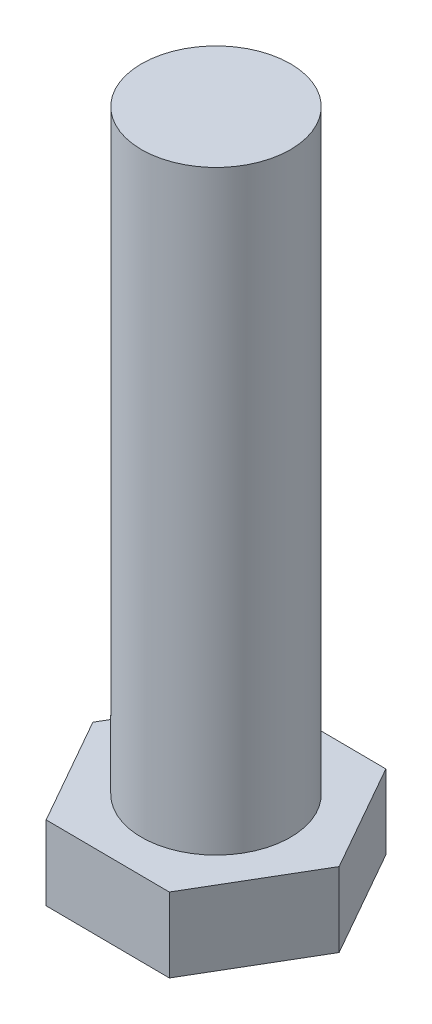
from build123d import *

# Parameters (mm, degrees)
SKETCH1_R           = 1.5
BOSS_EXTRUDE1_DEPTH = 12
BOSS_EXTRUDE2_DEPTH = 1.5


with BuildPart() as part:
    # Sketch1 → Boss-Extrude1 (new body)
    with BuildSketch(Plane(origin=(0, 0, 0), x_dir=(1, 0, 0), z_dir=(0, 1, 0))):
        Circle(SKETCH1_R)
    extrude(amount=BOSS_EXTRUDE1_DEPTH)

    # Sketch2 → Boss-Extrude2 (add)
    with BuildSketch(Plane.XZ):
        Polygon((2.5, 0.018896825), (1.23363487, 2.174511922), (-1.26636513, 2.155615097), (-2.5, -0.018896825), (-1.23363487, -2.174511922), (1.26636513, -2.155615097), align=None)
    extrude(amount=BOSS_EXTRUDE2_DEPTH)


solid = part.part
